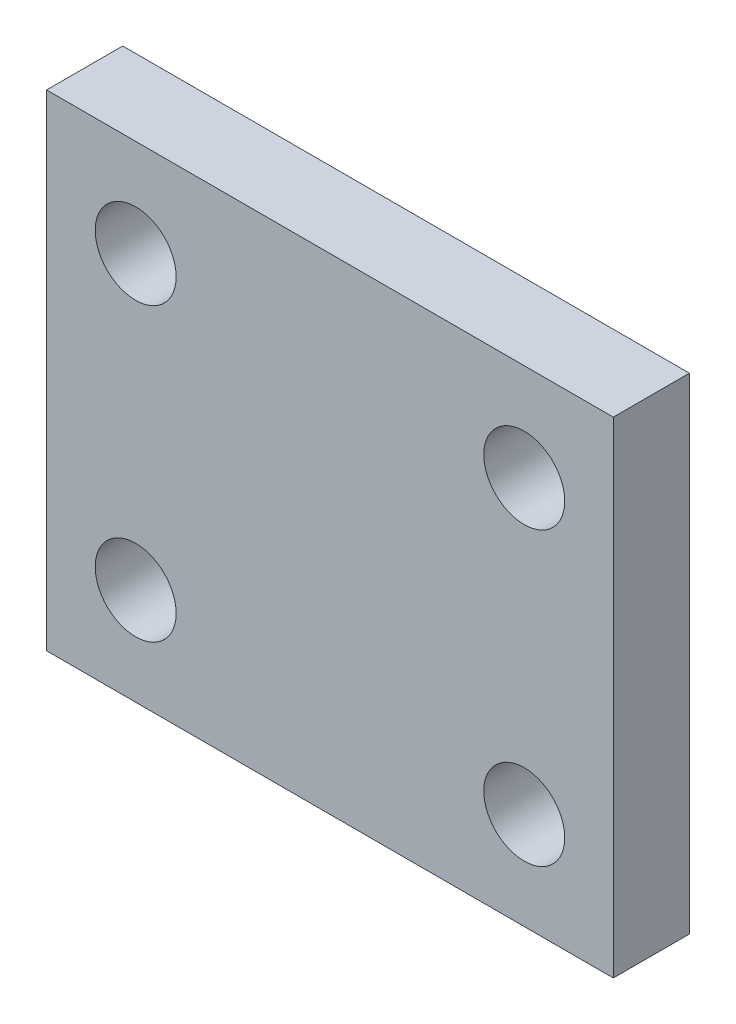
from build123d import *

# Parameters (mm, degrees)
SKETCH1_W           = 35
SKETCH1_H           = 30
SKETCH1_R           = 2.5
BOSS_EXTRUDE1_DEPTH = 4.7


with BuildPart() as part:
    # Sketch1 → Boss-Extrude1 (new body)
    with BuildSketch(Plane.XY):
        with Locations((17.5, 15)):
            Rectangle(SKETCH1_W, SKETCH1_H)
        with Locations((5.5, 24)):
            Circle(SKETCH1_R, mode=Mode.SUBTRACT)
        with Locations((29.5, 24)):
            Circle(SKETCH1_R, mode=Mode.SUBTRACT)
        with Locations((5.5, 6)):
            Circle(SKETCH1_R, mode=Mode.SUBTRACT)
        with Locations((29.5, 6)):
            Circle(SKETCH1_R, mode=Mode.SUBTRACT)
    extrude(amount=BOSS_EXTRUDE1_DEPTH)


solid = part.part
